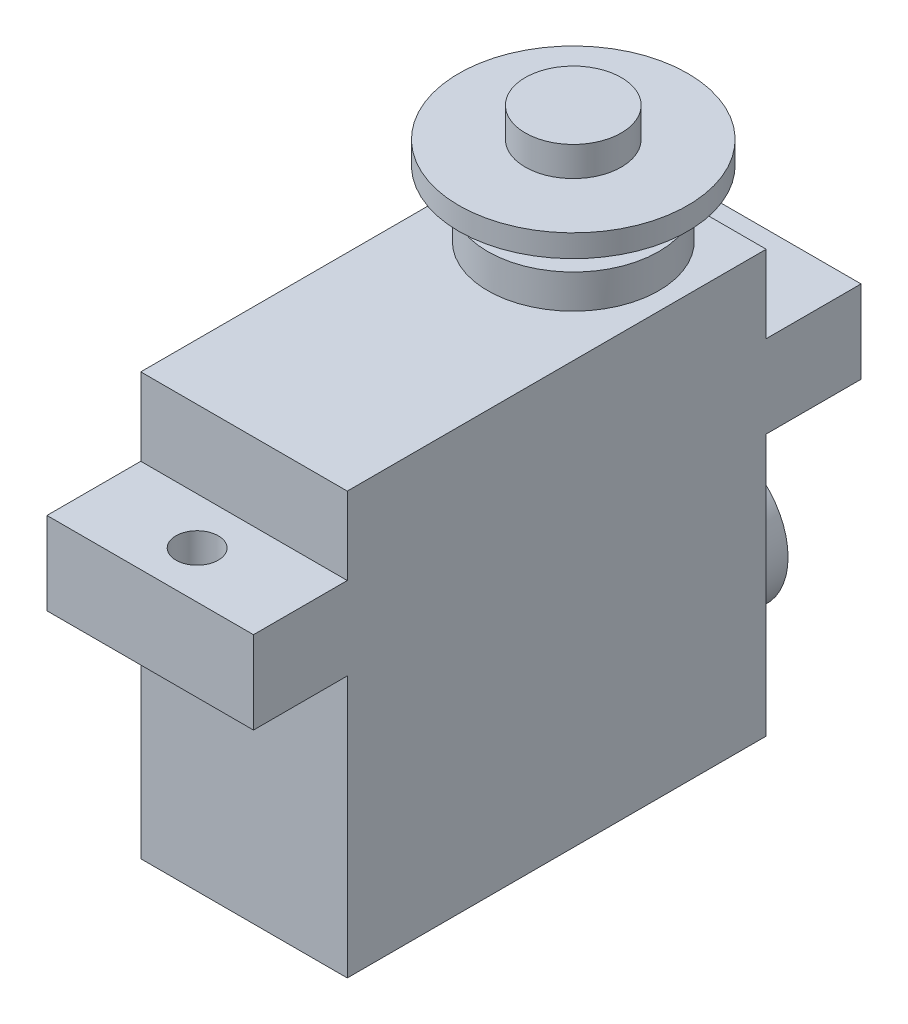
from build123d import *

# Parameters (mm, degrees)
SKETCH1_W                = 15.24
SKETCH1_H                = 30.9118
BOSS_EXTRUDE1_DEPTH      = 31.115
SKETCH2_W                = 15.24
SKETCH2_H                = 6.096
BOSS_EXTRUDE2_DEPTH      = 6.9215
BOSS_EXTRUDE2_DEPTH_BACK = 37.9095
SKETCH3_R                = 5.2705
BOSS_EXTRUDE3_DEPTH      = 3.9624
SKETCH4_R                = 6.3119
BOSS_EXTRUDE4_DEPTH      = 2.5019
SKETCH5_R                = 3.99415
BOSS_EXTRUDE5_DEPTH      = 2.3622
SKETCH6_R                = 8.4455
BOSS_EXTRUDE6_DEPTH      = 1.651
SKETCH7_R                = 3.5433
BOSS_EXTRUDE7_DEPTH      = 2.1844
CUT_EXTRUDE1_REACH       = 27.4
SKETCH8_R                = 1.5621
CUT_EXTRUDE2_REACH       = 27.4
SKETCH9_R                = 1.5621


with BuildPart() as part:
    # Sketch1 → Boss-Extrude1 (new body)
    with BuildSketch(Plane(origin=(0, 0, 0), x_dir=(1, 0, 0), z_dir=(0, 1, 0))):
        with Locations((7.62, 15.4559)):
            Rectangle(SKETCH1_W, SKETCH1_H)
    extrude(amount=BOSS_EXTRUDE1_DEPTH)

    # Sketch2 → Boss-Extrude2 (add, two sides)
    with BuildSketch(Plane.XY) as boss_extrude2_sk:
        with Locations((7.62, 22.352)):
            Rectangle(SKETCH2_W, SKETCH2_H)
    extrude(amount=BOSS_EXTRUDE2_DEPTH)
    extrude(boss_extrude2_sk.sketch, amount=-BOSS_EXTRUDE2_DEPTH_BACK)

    # Sketch3 → Boss-Extrude3 (add)
    with BuildSketch(Plane(origin=(0, 0, -30.9118), x_dir=(-1, 0, 0), z_dir=(0, 0, -1))):
        with Locations((-7.62, 8.2804)):
            Circle(SKETCH3_R)
    extrude(amount=BOSS_EXTRUDE3_DEPTH)

    # Sketch4 → Boss-Extrude4 (add)
    with BuildSketch(Plane(origin=(0, 31.115, 0), x_dir=(1, 0, 0), z_dir=(0, 1, 0))):
        with Locations((7.62, 24.2951)):
            Circle(SKETCH4_R)
    extrude(amount=BOSS_EXTRUDE4_DEPTH)

    # Sketch5 → Boss-Extrude5 (add)
    with BuildSketch(Plane(origin=(0, 33.6169, 0), x_dir=(1, 0, 0), z_dir=(0, 1, 0))):
        with Locations((7.62, 24.2951)):
            Circle(SKETCH5_R)
    extrude(amount=BOSS_EXTRUDE5_DEPTH)

    # Sketch6 → Boss-Extrude6 (add)
    with BuildSketch(Plane(origin=(0, 35.9791, 0), x_dir=(1, 0, 0), z_dir=(0, 1, 0))):
        with Locations((7.62, 24.2951)):
            Circle(SKETCH6_R)
    extrude(amount=BOSS_EXTRUDE6_DEPTH)

    # Sketch7 → Boss-Extrude7 (add)
    with BuildSketch(Plane(origin=(0, 37.6301, 0), x_dir=(1, 0, 0), z_dir=(0, 1, 0))):
        with Locations((7.62, 24.2951)):
            Circle(SKETCH7_R)
    extrude(amount=BOSS_EXTRUDE7_DEPTH)

    # Sketch8 → Cut-Extrude1 (cut, up to next)
    with BuildSketch(Plane(origin=(0, 25.4, 0), x_dir=(1, 0, 0), z_dir=(0, 1, 0)), mode=Mode.PRIVATE) as cut_extrude1_sk1:
        with Locations((7.62, -3.46075)):
            Circle(SKETCH8_R)
    cut_extrude1_tool1 = extrude(cut_extrude1_sk1.sketch, amount=-CUT_EXTRUDE1_REACH, mode=Mode.PRIVATE) & part.part
    add(cut_extrude1_tool1.solids().sort_by_distance((7.62, 25.4, 3.46075))[0], mode=Mode.SUBTRACT)

    # Sketch9 → Cut-Extrude2 (cut, up to next)
    with BuildSketch(Plane(origin=(0, 25.4, 0), x_dir=(1, 0, 0), z_dir=(0, 1, 0)), mode=Mode.PRIVATE) as cut_extrude2_sk1:
        with Locations((7.62, 34.41065)):
            Circle(SKETCH9_R)
    cut_extrude2_tool1 = extrude(cut_extrude2_sk1.sketch, amount=-CUT_EXTRUDE2_REACH, mode=Mode.PRIVATE) & part.part
    add(cut_extrude2_tool1.solids().sort_by_distance((7.62, 25.4, -34.41065))[0], mode=Mode.SUBTRACT)


solid = part.part
